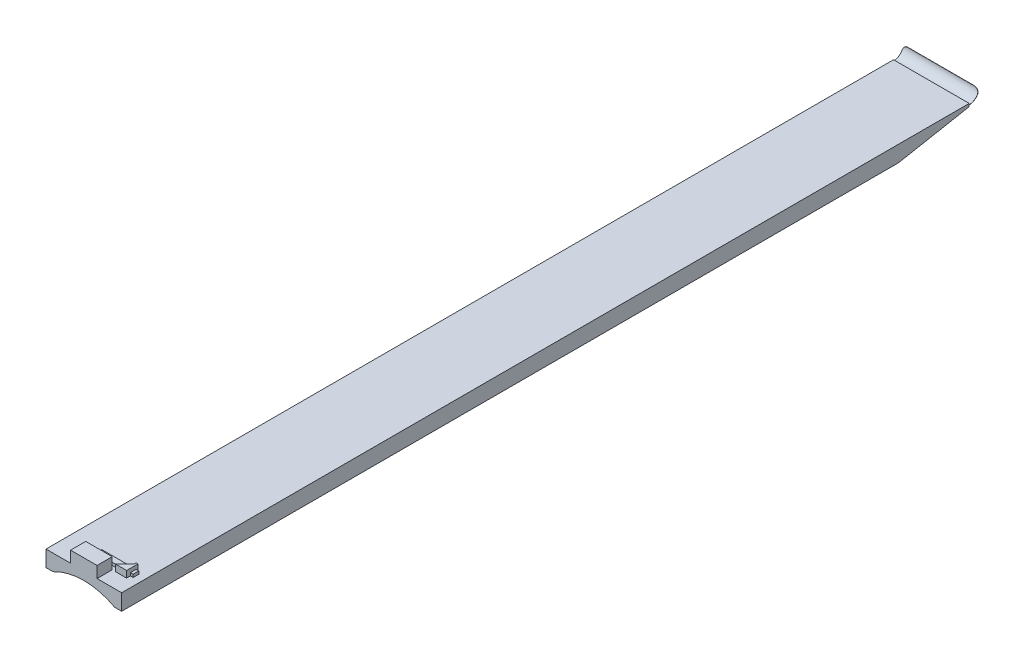
from build123d import *

# Parameters (mm, degrees)
BOSS_EXTRUDE1_DEPTH = 254
CUT_EXTRUDE1_DEPTH  = 2878.185
SKETCH6_R           = 217.8177
CUT_EXTRUDE2_DEPTH  = 2878.1850001
SKETCH7_W           = 88.9
SKETCH7_H           = 50.8
BOSS_EXTRUDE2_DEPTH = 38.1
BOSS_EXTRUDE3_DEPTH = 9.525
BOSS_EXTRUDE4_DEPTH = 12.7


with BuildPart() as part:
    # Sketch3 → Boss-Extrude1 (new body)
    with BuildSketch(Plane(origin=(0, 0, 0), x_dir=(0, 0, -1), z_dir=(1, 0, 0))):
        with BuildLine():
            Line((2844.8, 44.45), (2607.629412658, 0))
            Line((2607.629412658, 0), (0, 0))
            Line((0, 0), (0, 53.975))
            Line((0, 53.975), (2844.8, 53.975))
            Line((2844.8, 53.975), (2844.8, 50.165))
            ThreePointArc((2844.8, 50.165), (2867.250640303, 59.464359697), (2876.55, 81.915))
            Line((2876.55, 81.915), (2877.185, 81.915))
            ThreePointArc((2877.185, 81.915), (2867.699653109, 59.015346891), (2844.8, 49.53))
            Line((2844.8, 49.53), (2844.8, 44.45))
        make_face()
    extrude(amount=-BOSS_EXTRUDE1_DEPTH)

    # Sketch5 → Cut-Extrude1 (cut, through all)
    with BuildSketch(Plane.XY):
        with BuildLine():
            Line((0, 65.7225), (0, 81.915))
            Line((0, 81.915), (-16.1925, 81.915))
            ThreePointArc((-16.1925, 81.915), (-4.742673446, 77.172326554), (0, 65.7225))
        make_face()
        with BuildLine():
            Line((-254, 65.7225), (-254, 81.915))
            Line((-254, 81.915), (-237.8075, 81.915))
            ThreePointArc((-237.8075, 81.915), (-249.257326554, 77.172326554), (-254, 65.7225))
        make_face()
    extrude(amount=-CUT_EXTRUDE1_DEPTH, mode=Mode.SUBTRACT)

    # Sketch6 → Cut-Extrude2 (cut, through all)
    with BuildSketch(Plane.XY):
        with Locations((-127, -191.7827)):
            Circle(SKETCH6_R)
    extrude(amount=-CUT_EXTRUDE2_DEPTH, mode=Mode.SUBTRACT)

    # Sketch7 → Boss-Extrude2 (add)
    with BuildSketch(Plane(origin=(0, 53.975, 0), x_dir=(1, 0, 0), z_dir=(0, 1, 0))):
        with Locations((-127, 25.4)):
            Rectangle(SKETCH7_W, SKETCH7_H)
    extrude(amount=BOSS_EXTRUDE2_DEPTH)

    # Sketch8 → Boss-Extrude3 (add)
    with BuildSketch(Plane(origin=(0, 53.975, 0), x_dir=(1, 0, 0), z_dir=(0, 1, 0))):
        Polygon((-34.219914215, 88.9), (-34.219914215, 82.55), (-25.075914215, 82.55), (-25.075914215, 63.5), (-34.219914215, 63.5), (-34.219914215, 50.8), (-72.319914215, 50.8), (-72.319914215, 63.5), (-148.900914215, 63.5), (-148.900914215, 82.55), (-40.569914215, 82.55), (-40.569914215, 88.9), align=None)
    extrude(amount=BOSS_EXTRUDE3_DEPTH)

    # Sketch9 → Boss-Extrude4 (add)
    with BuildSketch(Plane(origin=(0, 63.5, 0), x_dir=(1, 0, 0), z_dir=(0, 1, 0))):
        Polygon((-72.319914215, 50.8), (-40.569914215, 82.55), (-40.569914215, 88.9), (-34.219914215, 88.9), (-34.219914215, 50.8), align=None)
    extrude(amount=BOSS_EXTRUDE4_DEPTH)


solid = part.part
